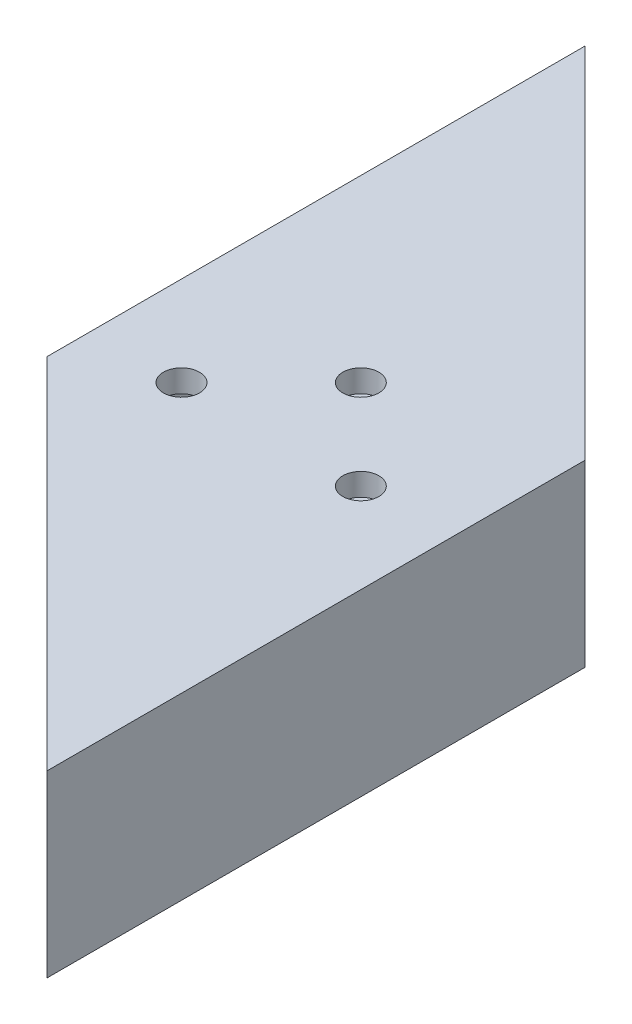
from build123d import *

# Parameters (mm, degrees)
SKETCH1_W           = 50.8
SKETCH1_H           = 25.4
SKETCH1_W_2         = 44.45
SKETCH1_H_2         = 19.05
BOSS_EXTRUDE1_DEPTH = 127
CUT_EXTRUDE1_DEPTH  = 127
SKETCH3_R           = 2.5527
CUT_EXTRUDE2_DEPTH  = 25.4


with BuildPart() as part:
    # Sketch1 → Boss-Extrude1 (new body)
    with BuildSketch(Plane.XY):
        with Locations((25.4, 12.7)):
            Rectangle(SKETCH1_W, SKETCH1_H)
        with Locations((25.4, 12.7)):
            Rectangle(SKETCH1_W_2, SKETCH1_H_2, mode=Mode.SUBTRACT)
    extrude(amount=BOSS_EXTRUDE1_DEPTH)

    # Sketch2 → Cut-Extrude1 (cut)
    with BuildSketch(Plane(origin=(0, 25.4, 0), x_dir=(1, 0, 0), z_dir=(0, 1, 0))):
        Polygon((0, 0), (50.8, -50.8), (50.8, 0), align=None)
        Polygon((0, -76.2), (0, -127), (50.8, -127), align=None)
    extrude(amount=-CUT_EXTRUDE1_DEPTH, mode=Mode.SUBTRACT)

    # Sketch3 → Cut-Extrude2 (cut)
    with BuildSketch(Plane(origin=(0, 25.4, 0), x_dir=(1, 0, 0), z_dir=(0, 1, 0))):
        with Locations((12.7, -69.85)):
            Circle(SKETCH3_R)
        with Locations((38.1, -69.85)):
            Circle(SKETCH3_R)
        with Locations((25.4, -57.15)):
            Circle(SKETCH3_R)
    extrude(amount=-CUT_EXTRUDE2_DEPTH, mode=Mode.SUBTRACT)


solid = part.part
